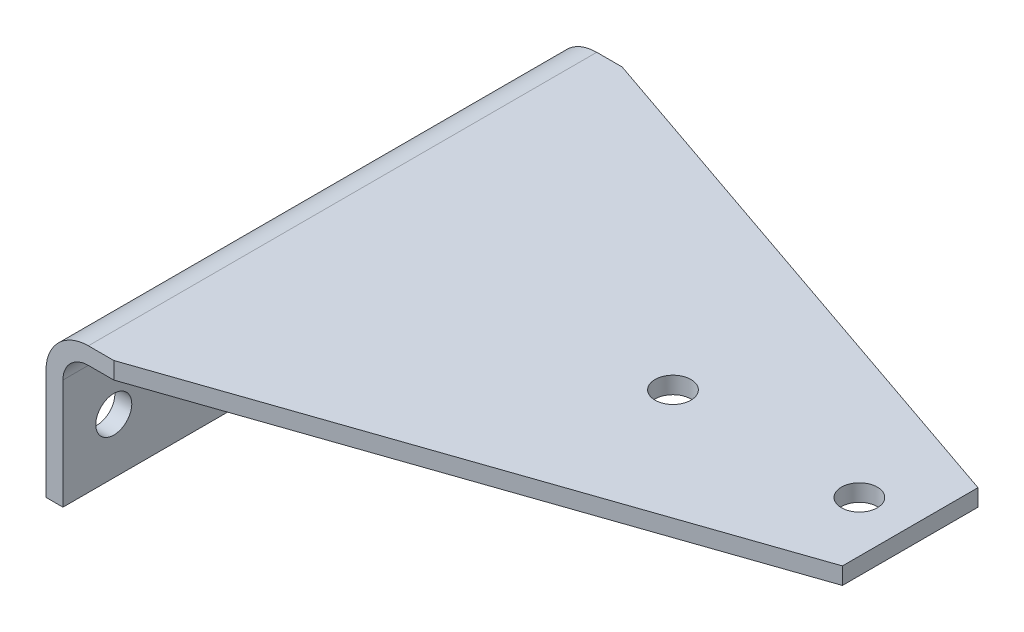
from build123d import *

# Parameters (mm, degrees)
EXTRUDE1_DEPTH         = 95.25
SKETCH2_R              = 6.731
CUT_CHAMFER_DEPTH      = 508
CUT_CHAMFER_DEPTH_BACK = 58.15
SKETCH3_R              = 6.746875
CUT_HOLES_DEPTH        = 229.6


with BuildPart() as part:
    # Sketch1 → Extrude1 (new body, symmetric)
    with BuildSketch(Plane.XY):
        with BuildLine():
            Line((228.6, 0), (15.875, 0))
            ThreePointArc((15.875, 0), (4.649679849, -4.649679849), (0, -15.875))
            Line((0, -15.875), (0, -57.15))
            Line((0, -57.15), (6.35, -57.15))
            Line((6.35, -57.15), (6.35, -15.875))
            ThreePointArc((6.35, -15.875), (9.139807909, -9.139807909), (15.875, -6.35))
            Line((15.875, -6.35), (228.6, -6.35))
            Line((228.6, -6.35), (228.6, 0))
        make_face()
    extrude(amount=EXTRUDE1_DEPTH, both=True)

    # Sketch2 → Cut-Chamfer (cut, two sides)
    with BuildSketch(Plane(origin=(0, 0, 0), x_dir=(1, 0, 0), z_dir=(0, 1, 0))) as cut_chamfer_sk:
        with Locations((209.55, 0)):
            Circle(SKETCH2_R)
        with Locations((139.7, 0)):
            Circle(SKETCH2_R)
        Polygon((25.4, 95.25), (228.6, 25.4), (228.6, 95.25), align=None)
        Polygon((25.4, -95.25), (228.6, -25.4), (228.6, -95.25), align=None)
    extrude(amount=CUT_CHAMFER_DEPTH, mode=Mode.SUBTRACT)
    extrude(cut_chamfer_sk.sketch, amount=-CUT_CHAMFER_DEPTH_BACK, mode=Mode.SUBTRACT)

    # Sketch3 → Cut-Holes (cut, through all)
    with BuildSketch(Plane(origin=(0, 0, 0), x_dir=(0, 0, -1), z_dir=(1, 0, 0))):
        with Locations((-76.2, -36.5125)):
            Circle(SKETCH3_R)
        with Locations((76.2, -36.5125)):
            Circle(SKETCH3_R)
    extrude(amount=CUT_HOLES_DEPTH, mode=Mode.SUBTRACT)


solid = part.part
